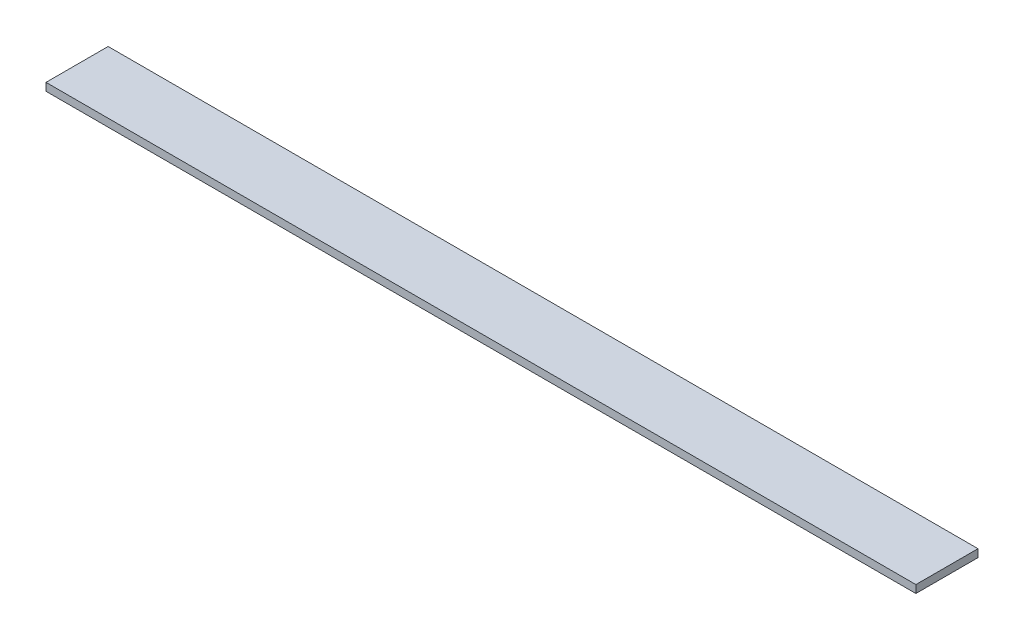
from build123d import *

# Parameters (mm, degrees)
SKETCH2_W           = 355.6
SKETCH2_H           = 25.4
BOSS_EXTRUDE1_DEPTH = 3.175


with BuildPart() as part:
    # Sketch2 → Boss-Extrude1 (new body)
    with BuildSketch(Plane(origin=(0, 0, 0), x_dir=(1, 0, 0), z_dir=(0, 1, 0))):
        Rectangle(SKETCH2_W, SKETCH2_H)
    extrude(amount=BOSS_EXTRUDE1_DEPTH)


solid = part.part
